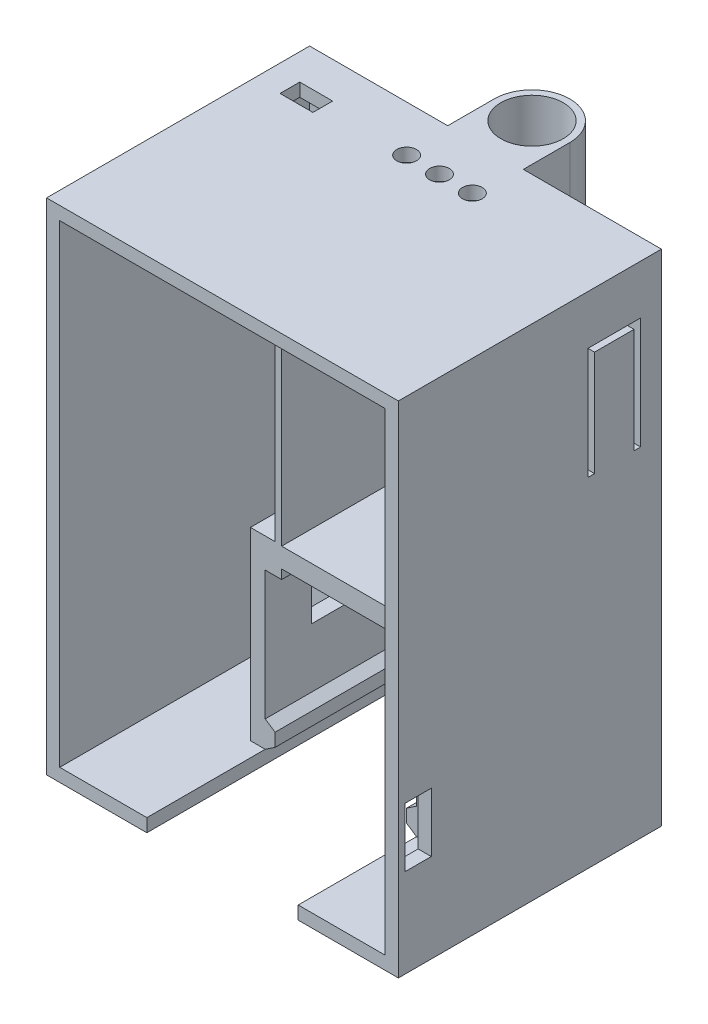
from build123d import *

# Parameters (mm, degrees)
SKETCH1_W            = 25.5
SKETCH1_H            = 72
BOSS_EXTRUDE1_DEPTH  = 2
SKETCH2_W            = 3.75
SKETCH2_H            = 5
SKETCH2_H_2          = 4
BOSS_EXTRUDE2_DEPTH  = 20
SKETCH3_W            = 18
SKETCH3_H            = 3
BOSS_EXTRUDE3_DEPTH  = 20
SKETCH4_W            = 3.75
SKETCH4_H            = 39.4
BOSS_EXTRUDE4_DEPTH  = 20
SKETCH9_W            = 1.25
SKETCH9_H            = 23.6
BOSS_EXTRUDE6_DEPTH  = 20
BOSS_EXTRUDE7_DEPTH  = 20
SKETCH15_W           = 12
SKETCH15_H           = 72
BOSS_EXTRUDE8_DEPTH  = 22
SKETCH16_W           = 53.5
SKETCH16_H           = 76
SKETCH16_W_2         = 49.5
SKETCH16_H_2         = 72
BOSS_EXTRUDE9_DEPTH  = 40
SKETCH17_W           = 9
SKETCH17_H           = 68
CUT_EXTRUDE1_DEPTH   = 20
SKETCH276_R          = 1.5
CUT_EXTRUDE2_DEPTH   = 3
CUT_EXTRUDE3_DEPTH   = 20
CUT_EXTRUDE4_REACH   = 55.5
SKETCH283_W          = 4
SKETCH283_H          = 9
CUT_EXTRUDE5_REACH   = 17.25
SKETCH287_W          = 5
SKETCH287_H          = 5
CUT_EXTRUDE6_REACH   = 42.5
SKETCH288_W          = 5
SKETCH288_H          = 5
CUT_EXTRUDE8_REACH   = 78
SKETCH291_W          = 5
SKETCH291_H          = 3
CUT_EXTRUDE9_REACH   = 55.5
CUT_EXTRUDE10_DEPTH  = 38
SKETCH297_R          = 4.75
BOSS_EXTRUDE10_DEPTH = 76


with BuildPart() as part:
    # Sketch1 → Boss-Extrude1 (new body)
    with BuildSketch(Plane.XY):
        with Locations((-20.131274131, -9.514285714)):
            Rectangle(SKETCH1_W, SKETCH1_H)
    extrude(amount=BOSS_EXTRUDE1_DEPTH)

    # Sketch2 → Boss-Extrude2 (add)
    with BuildSketch(Plane.XY.offset(2)):
        with Locations((-31.006274131, 23.985714286)):
            Rectangle(SKETCH2_W, SKETCH2_H)
        with Locations((-31.006274131, -19.914285714)):
            Rectangle(SKETCH2_W, SKETCH2_H_2)
        with Locations((-9.256274131, -19.914285714)):
            Rectangle(SKETCH2_W, SKETCH2_H_2)
        with Locations((-9.256274131, 23.985714286)):
            Rectangle(SKETCH2_W, SKETCH2_H)
    extrude(amount=BOSS_EXTRUDE2_DEPTH)

    # Sketch3 → Boss-Extrude3 (add)
    with BuildSketch(Plane.XY.offset(2)):
        with Locations((-20.131274131, -19.014285714)):
            Rectangle(SKETCH3_W, SKETCH3_H)
    extrude(amount=BOSS_EXTRUDE3_DEPTH)

    # Sketch4 → Boss-Extrude4 (add)
    with BuildSketch(Plane.XY.offset(2)):
        with Locations((-31.006274131, 1.785714286)):
            Rectangle(SKETCH4_W, SKETCH4_H)
        with Locations((-9.256274131, 1.785714286)):
            Rectangle(SKETCH4_W, SKETCH4_H)
    extrude(amount=BOSS_EXTRUDE4_DEPTH)

    # Sketch9 → Boss-Extrude6 (add)
    with BuildSketch(Plane.XY.offset(2)):
        with Locations((-32.256274131, -33.714285714)):
            Rectangle(SKETCH9_W, SKETCH9_H)
        with Locations((-8.006274131, -33.714285714)):
            Rectangle(SKETCH9_W, SKETCH9_H)
    extrude(amount=BOSS_EXTRUDE6_DEPTH)

    # Sketch11 → Boss-Extrude7 (add)
    with BuildSketch(Plane.XY.offset(2)):
        Polygon((-31.631274131, -45.514285714), (-30.131274131, -44.514285714), (-30.131274131, -42.514285714), (-31.631274131, -41.514285714), align=None)
        Polygon((-8.631274131, -45.514285714), (-10.131274131, -44.514285714), (-10.131274131, -42.514285714), (-8.631274131, -41.514285714), align=None)
    extrude(amount=BOSS_EXTRUDE7_DEPTH)

    # Sketch15 → Boss-Extrude8 (add)
    with BuildSketch(Plane(origin=(0, 0, 0), x_dir=(-1, 0, 0), z_dir=(0, 0, -1))):
        with Locations((38.881274131, -9.514285714)):
            Rectangle(SKETCH15_W, SKETCH15_H)
        with Locations((1.381274131, -9.514285714)):
            Rectangle(SKETCH15_W, SKETCH15_H)
    extrude(amount=-BOSS_EXTRUDE8_DEPTH)

    # Sketch16 → Boss-Extrude9 (add)
    with BuildSketch(Plane(origin=(0, 0, 0), x_dir=(-1, 0, 0), z_dir=(0, 0, -1))):
        with Locations((20.131274131, -9.514285714)):
            Rectangle(SKETCH16_W, SKETCH16_H)
        with Locations((20.131274131, -9.514285714)):
            Rectangle(SKETCH16_W_2, SKETCH16_H_2, mode=Mode.SUBTRACT)
    extrude(amount=-BOSS_EXTRUDE9_DEPTH)

    # Sketch17 → Cut-Extrude1 (cut)
    with BuildSketch(Plane.XY.offset(22)):
        with Locations((-38.381274131, -9.514285714)):
            Rectangle(SKETCH17_W, SKETCH17_H)
        with Locations((-1.881274131, -9.514285714)):
            Rectangle(SKETCH17_W, SKETCH17_H)
    extrude(amount=-CUT_EXTRUDE1_DEPTH, mode=Mode.SUBTRACT)

    # Sketch276 → Cut-Extrude2 (cut, through all)
    with BuildSketch(Plane.XZ.offset(-26.485714286)):
        with Locations((-25.131274131, 7)):
            Circle(SKETCH276_R)
        with Locations((-15.131274131, 7)):
            Circle(SKETCH276_R)
        with Locations((-20.131274131, 7)):
            Circle(SKETCH276_R)
    extrude(amount=-CUT_EXTRUDE2_DEPTH, mode=Mode.SUBTRACT)

    # Sketch282 → Cut-Extrude3 (cut)
    with BuildSketch(Plane.XY.offset(22)):
        Polygon((-33.881274131, -17.418411546), (-30.131274131, -17.418411546), (-30.131274131, 26.485714286), (-44.881274131, 26.485714286), (-44.881274131, -45.514285714), (-33.881274131, -45.514285714), align=None)
        Polygon((-10.131274131, 26.485714286), (-10.131274131, -17.514285714), (-6.381274131, -17.514285714), (-6.381274131, -45.514285714), (4.618725869, -45.514285714), (4.618725869, 26.485714286), align=None)
    extrude(amount=-CUT_EXTRUDE3_DEPTH, mode=Mode.SUBTRACT)

    # Sketch283 → Cut-Extrude4 (cut, up to next)
    with BuildSketch(Plane(origin=(6.618725869, 0, 0), x_dir=(0, 0, -1), z_dir=(1, 0, 0)), mode=Mode.PRIVATE) as cut_extrude4_sk1:
        with Locations((-37, -29.514285714)):
            Rectangle(SKETCH283_W, SKETCH283_H)
    cut_extrude4_tool1 = extrude(cut_extrude4_sk1.sketch, amount=-CUT_EXTRUDE4_REACH, mode=Mode.PRIVATE) & part.part
    add(cut_extrude4_tool1.solids().sort_by_distance((6.618726, -29.514286, 37))[0], mode=Mode.SUBTRACT)

    # Sketch287 → Cut-Extrude5 (cut, up to next)
    with BuildSketch(Plane(origin=(-31.631274131, 0, 0), x_dir=(0, 0, -1), z_dir=(1, 0, 0)), mode=Mode.PRIVATE) as cut_extrude5_sk1:
        with Locations((-12.5, -30.014285714)):
            Rectangle(SKETCH287_W, SKETCH287_H)
    cut_extrude5_tool1 = extrude(cut_extrude5_sk1.sketch, amount=-CUT_EXTRUDE5_REACH, mode=Mode.PRIVATE) & part.part
    add(cut_extrude5_tool1.solids().sort_by_distance((-31.631274, -30.014286, 12.5))[0], mode=Mode.SUBTRACT)

    # Sketch288 → Cut-Extrude6 (cut, up to next)
    with BuildSketch(Plane(origin=(-6.381274131, 0, 0), x_dir=(0, 0, -1), z_dir=(1, 0, 0)), mode=Mode.PRIVATE) as cut_extrude6_sk1:
        with Locations((-12.5, -30.014285714)):
            Rectangle(SKETCH288_W, SKETCH288_H)
    cut_extrude6_tool1 = extrude(cut_extrude6_sk1.sketch, amount=-CUT_EXTRUDE6_REACH, mode=Mode.PRIVATE) & part.part
    add(cut_extrude6_tool1.solids().sort_by_distance((-6.381274, -30.014286, 12.5))[0], mode=Mode.SUBTRACT)

    # Sketch291 → Cut-Extrude8 (cut, up to next)
    with BuildSketch(Plane(origin=(0, 28.485714286, 0), x_dir=(1, 0, 0), z_dir=(0, 1, 0)), mode=Mode.PRIVATE) as cut_extrude8_sk1:
        with Locations((-40.381274131, -7)):
            Rectangle(SKETCH291_W, SKETCH291_H)
    cut_extrude8_tool1 = extrude(cut_extrude8_sk1.sketch, amount=-CUT_EXTRUDE8_REACH, mode=Mode.PRIVATE) & part.part
    add(cut_extrude8_tool1.solids().sort_by_distance((-40.381274, 28.485714, 7))[0], mode=Mode.SUBTRACT)

    # Sketch292 → Cut-Extrude9 (cut, up to next)
    with BuildSketch(Plane(origin=(6.618725869, 0, 0), x_dir=(0, 0, -1), z_dir=(1, 0, 0)), mode=Mode.PRIVATE) as cut_extrude9_sk1:
        Polygon((-10.165543533, 4.001752047), (-11.165543533, 4.001752047), (-11.165543533, 21.001752047), (-3.165543533, 21.001752047), (-3.165543533, 4.001752047), (-4.165543533, 4.001752047), (-4.165543533, 5.001752047), (-4.165543533, 20.001752047), (-10.165543533, 20.001752047), (-10.165543533, 5.001752047), align=None)
    cut_extrude9_tool1 = extrude(cut_extrude9_sk1.sketch, amount=-CUT_EXTRUDE9_REACH, mode=Mode.PRIVATE) & part.part
    add(cut_extrude9_tool1.solids().sort_by_distance((6.618726, 4.189635, 10.665544))[0], mode=Mode.SUBTRACT)

    # Sketch295 → Cut-Extrude10 (cut)
    with BuildSketch(Plane.XY.offset(40)):
        Polygon((-31.631274131, -47.514285714), (-8.614465399, -47.514285714), (-8.614465399, -45.514285714), (-8.631274131, -45.514285714), (-31.631274131, -45.514285714), align=None)
    extrude(amount=-CUT_EXTRUDE10_DEPTH, mode=Mode.SUBTRACT)

    # Sketch297 → Boss-Extrude10 (add)
    with BuildSketch(Plane(origin=(0, 28.485714286, 0), x_dir=(1, 0, 0), z_dir=(0, 1, 0))):
        with BuildLine():
            Line((-25.881274131, 0), (-14.381274131, 0))
            Line((-14.381274131, 0), (-14.381274131, 7.071463376))
            ThreePointArc((-14.381274131, 7.071463376), (-20.131274131, 12.821463376), (-25.881274131, 7.071463376))
            Line((-25.881274131, 7.071463376), (-25.881274131, 0))
        make_face()
        with Locations((-20.131274131, 7.071463376)):
            Circle(SKETCH297_R, mode=Mode.SUBTRACT)
    extrude(amount=-BOSS_EXTRUDE10_DEPTH)


solid = part.part
